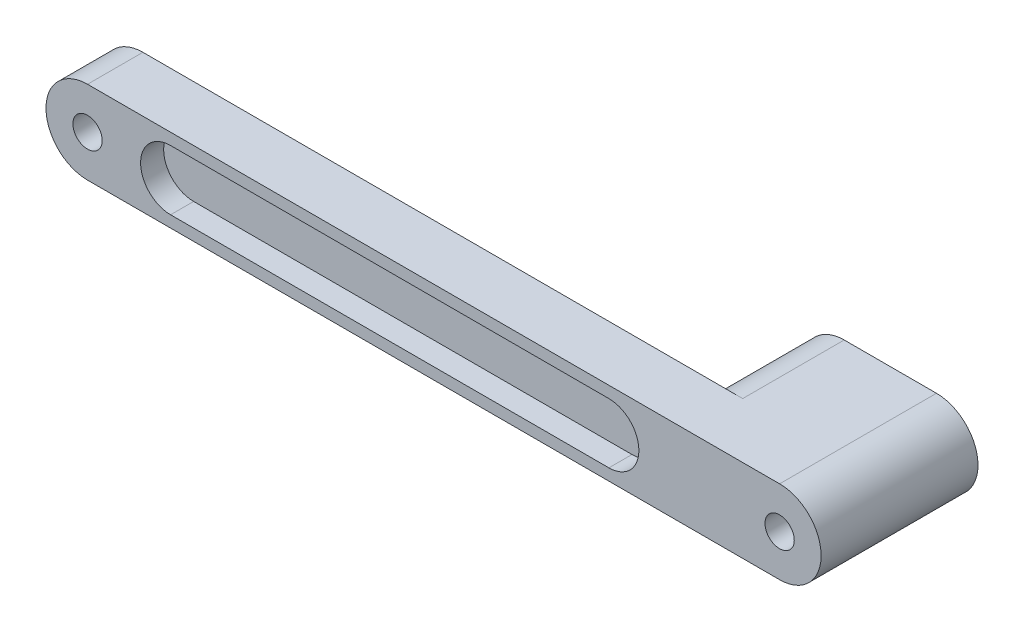
from build123d import *

# Parameters (mm, degrees)
SKETCH1_R           = 3.175
BOSS_EXTRUDE1_DEPTH = 12
SKETCH2_R           = 3.175
BOSS_EXTRUDE2_DEPTH = 22
CUT_EXTRUDE1_DEPTH  = 5
CUT_EXTRUDE2_DEPTH  = 30


with BuildPart() as part:
    # Sketch1 → Boss-Extrude1 (new body)
    with BuildSketch(Plane.XY):
        with BuildLine():
            Line((0, 9), (150, 9))
            ThreePointArc((150, 9), (159, 0), (150, -9))
            Line((150, -9), (0, -9))
            ThreePointArc((0, -9), (-9, 0), (0, 9))
        make_face()
        Circle(SKETCH1_R, mode=Mode.SUBTRACT)
        with Locations((150, 0)):
            Circle(SKETCH1_R, mode=Mode.SUBTRACT)
    extrude(amount=BOSS_EXTRUDE1_DEPTH)

    # Sketch2 → Boss-Extrude2 (add)
    with BuildSketch(Plane(origin=(0, 0, 0), x_dir=(-1, 0, 0), z_dir=(0, 0, -1))):
        with BuildLine():
            Line((-150, 9), (-130, 9))
            ThreePointArc((-130, 9), (-121, 0), (-130, -9))
            Line((-130, -9), (-150, -9))
            ThreePointArc((-150, -9), (-159, 0), (-150, 9))
        make_face()
        with Locations((-150, 0)):
            Circle(SKETCH2_R, mode=Mode.SUBTRACT)
    extrude(amount=BOSS_EXTRUDE2_DEPTH)

    # Sketch3 → Cut-Extrude1 (cut)
    with BuildSketch(Plane.XY.offset(12)):
        with BuildLine():
            Line((18, 6.5), (113, 6.5))
            ThreePointArc((113, 6.5), (119.5, 0), (113, -6.5))
            Line((113, -6.5), (18, -6.5))
            ThreePointArc((18, -6.5), (11.5, 0), (18, 6.5))
        make_face()
    cut_extrude1 = extrude(amount=-CUT_EXTRUDE1_DEPTH, mode=Mode.SUBTRACT)

    # Mirror1: Cut-Extrude1 across plane
    add(cut_extrude1.mirror(Plane.XY.offset(6)), mode=Mode.SUBTRACT)

    # Sketch4 → Cut-Extrude2 (cut)
    with BuildSketch(Plane(origin=(0, 0, -22), x_dir=(-1, 0, 0), z_dir=(0, 0, -1))):
        with BuildLine():
            Line((-130, 6), (-138, 6))
            ThreePointArc((-138, 6), (-144, 0), (-138, -6))
            Line((-138, -6), (-130, -6))
            ThreePointArc((-130, -6), (-124, 0), (-130, 6))
        make_face()
    extrude(amount=-CUT_EXTRUDE2_DEPTH, mode=Mode.SUBTRACT)


solid = part.part
